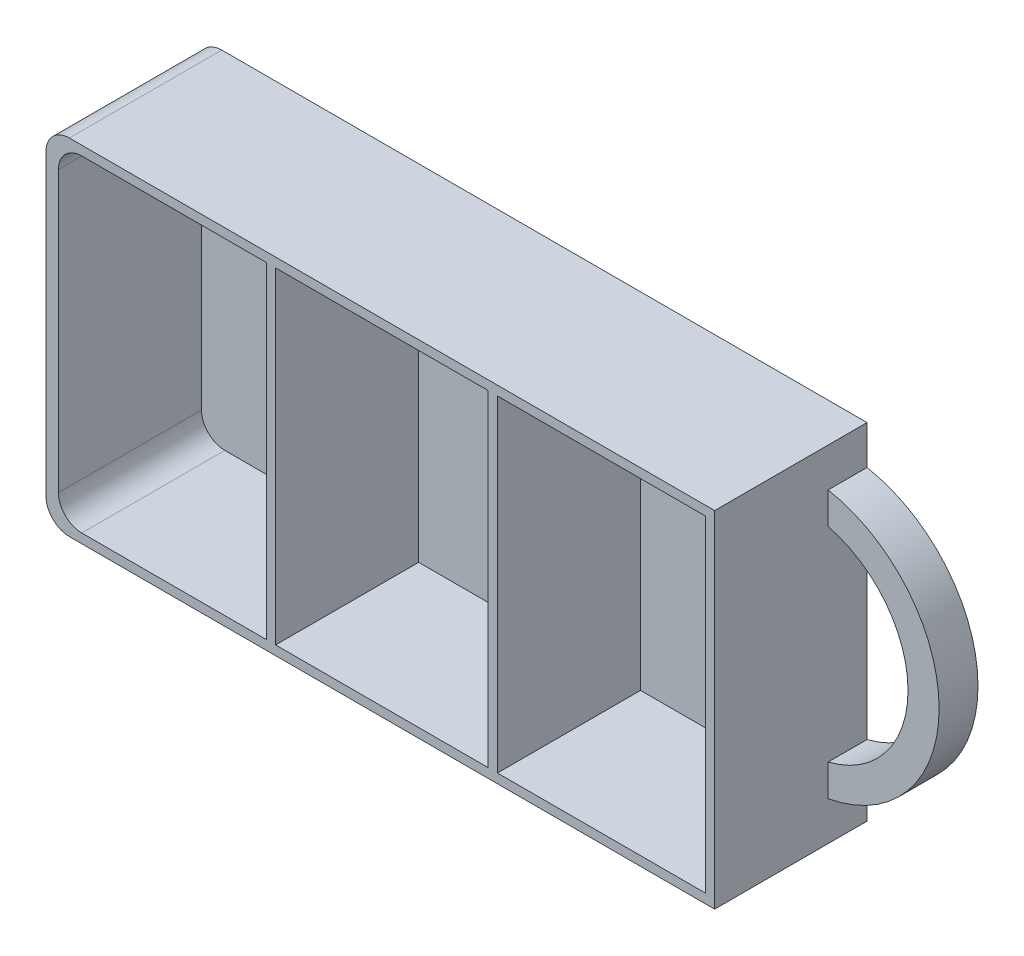
from build123d import *

# Parameters (mm, degrees)
SKETCH_1_W          = 86
SKETCH_1_H          = 44.4
EXTRUDE_1_DEPTH     = 19.6
EXTRUDE_2_DEPTH     = 5
SKETCH_3_W          = 26.733333333
SKETCH_3_H          = 42
SKETCH_3_W_2        = 27.333333334
CUT_EXTRUDE_1_DEPTH = 18.4
FILLET_1_R          = 3


with BuildPart() as part:
    # Эскиз1 → Бобышка-Вытянуть1 (new body)
    with BuildSketch(Plane.XY):
        Rectangle(SKETCH_1_W, SKETCH_1_H)
    extrude(amount=EXTRUDE_1_DEPTH)

    # Эскиз2 → Бобышка-Вытянуть2 (add)
    with BuildSketch(Plane.XY):
        with BuildLine():
            Line((43, 17.2), (43, 13.108775687))
            ThreePointArc((43, 13.108775687), (53.273546839, 0), (43, -13.108775687))
            Line((43, -13.108775687), (43, -17.2))
            ThreePointArc((43, -17.2), (57.273546839, 0), (43, 17.2))
        make_face()
    extrude(amount=EXTRUDE_2_DEPTH)

    # Эскиз3 → Вырез-Вытянуть1 (cut)
    with BuildSketch(Plane.XY.offset(19.6)):
        with Locations((-28.033333334, 0)):
            Rectangle(SKETCH_3_W, SKETCH_3_H)
        with Locations((0.2, 0)):
            Rectangle(SKETCH_3_W_2, SKETCH_3_H)
        with Locations((28.433333334, 0)):
            Rectangle(SKETCH_3_W, SKETCH_3_H)
    extrude(amount=-CUT_EXTRUDE_1_DEPTH, mode=Mode.SUBTRACT)

    # Скругление1
    fillet_1_edges = [part.edges().sort_by_distance(p)[0] for p in [
        (-41.4, 21, 10.4),
        (-41.4, -21, 10.4),
        (-43, -22.2, 9.8),
        (-43, 22.2, 9.8),
    ]]
    fillet(fillet_1_edges, radius=FILLET_1_R)


solid = part.part
